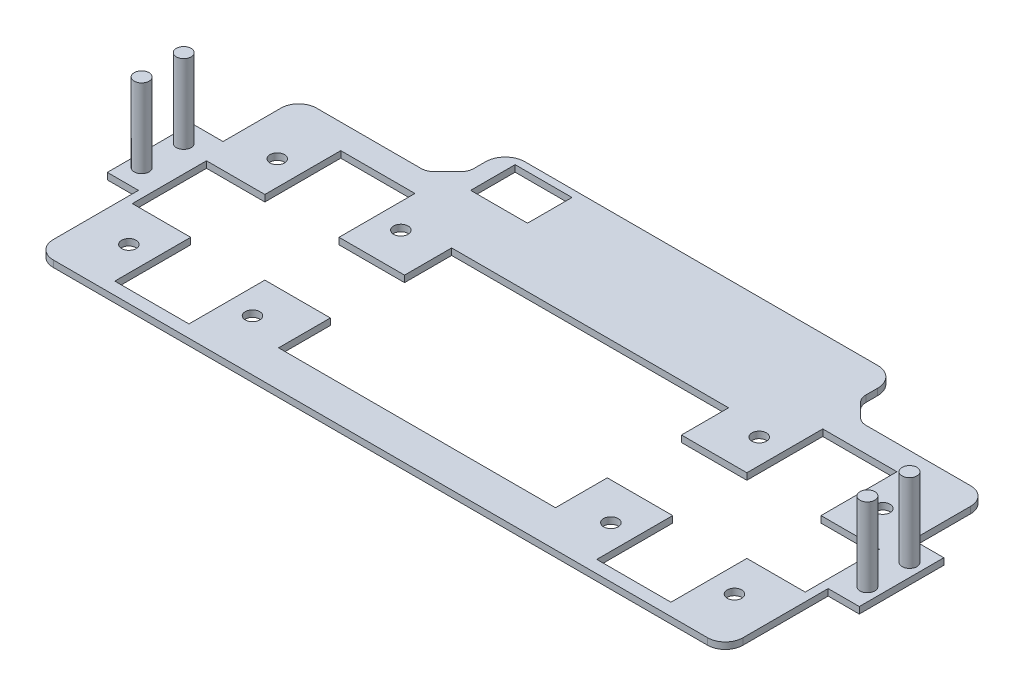
from build123d import *

# Parameters (mm, degrees)
BOSS_EXTRUDE1_DEPTH = 5
SCALE2_SCALE        = 0.265
SKETCH6_W           = 6.3
SKETCH6_H           = 17.1
BOSS_EXTRUDE2_DEPTH = 1.325
SKETCH5_W           = 11.5
SKETCH5_H           = 9
SKETCH5_R           = 1.468522593
CUT_EXTRUDE1_DEPTH  = 1.325
SKETCH8_R           = 1.5
BOSS_EXTRUDE5_DEPTH = 15.9


with BuildPart() as part:
    # Sketch1 → Boss-Extrude1 (new body)
    with BuildSketch(Plane(origin=(0, 0, 0), x_dir=(1, 0, 0), z_dir=(0, 1, 0))):
        with BuildLine():
            Line((-247.677130459, 9.093460821), (0, 9.093460821))
            Line((0, 9.093460821), (1.981474539, 9.093460821))
            Line((1.981474539, 9.093460821), (3.962949079, 9.093460821))
            Line((3.962949079, 9.093460821), (251.640079537, 9.093460821))
            ThreePointArc((251.640079537, 9.093460821), (261.186021083, 13.047519275), (265.140079537, 22.593460821))
            Line((265.140079537, 22.593460821), (265.140079537, 87.593460821))
            Line((265.140079537, 87.593460821), (265.140079537, 152.207743366))
            Line((265.140079537, 152.207743366), (265.140079537, 196.397667024))
            ThreePointArc((265.140079537, 196.397667024), (261.186021083, 205.94360857), (251.640079537, 209.897667024))
            Line((251.640079537, 209.897667024), (171.71214435, 209.897667024))
            ThreePointArc((171.71214435, 209.897667024), (167.885310027, 210.658871699), (164.641076538, 212.826599212))
            Line((164.641076538, 212.826599212), (154.53187981, 222.935795941))
            ThreePointArc((154.53187981, 222.935795941), (152.364152296, 226.180029429), (151.602947621, 230.006863753))
            Line((151.602947621, 230.006863753), (151.602947621, 238.96110688))
            ThreePointArc((151.602947621, 238.96110688), (147.209549339, 249.567708598), (136.602947621, 253.96110688))
            Line((136.602947621, 253.96110688), (3.962949079, 253.96110688))
            Line((3.962949079, 253.96110688), (0, 253.96110688))
            Line((0, 253.96110688), (-132.639998543, 253.96110688))
            ThreePointArc((-132.639998543, 253.96110688), (-143.246600261, 249.567708598), (-147.639998543, 238.96110688))
            Line((-147.639998543, 238.96110688), (-147.639998543, 230.006863753))
            ThreePointArc((-147.639998543, 230.006863753), (-148.401203218, 226.180029429), (-150.568930731, 222.935795941))
            Line((-150.568930731, 222.935795941), (-160.67812746, 212.826599212))
            ThreePointArc((-160.67812746, 212.826599212), (-163.922360948, 210.658871699), (-167.749195272, 209.897667024))
            Line((-167.749195272, 209.897667024), (-247.677130459, 209.897667024))
            ThreePointArc((-247.677130459, 209.897667024), (-257.223072005, 205.94360857), (-261.177130459, 196.397667024))
            Line((-261.177130459, 196.397667024), (-261.177130459, 152.207743366))
            Line((-261.177130459, 152.207743366), (-261.177130459, 87.593460821))
            Line((-261.177130459, 87.593460821), (-261.177130459, 22.593460821))
            ThreePointArc((-261.177130459, 22.593460821), (-257.223072005, 13.047519275), (-247.677130459, 9.093460821))
        make_face()
    extrude(amount=BOSS_EXTRUDE1_DEPTH)


with BuildPart() as part_1:
    # Scale2: scaled about (0, 0, 0)
    add(part.part.scale(SCALE2_SCALE))

    # Sketch6 → Boss-Extrude2 (add)
    with BuildSketch(Plane(origin=(0, 1.325, 0), x_dir=(1, 0, 0), z_dir=(0, 1, 0))):
        with Locations((-72.361939572, 31.762267118)):
            Rectangle(SKETCH6_W, SKETCH6_H)
        with Locations((73.412121077, 31.762267118)):
            Rectangle(SKETCH6_W, SKETCH6_H)
    extrude(amount=-BOSS_EXTRUDE2_DEPTH)

    # Sketch5 → Cut-Extrude1 (cut)
    with BuildSketch(Plane(origin=(0, 1.325, 0), x_dir=(1, 0, 0), z_dir=(0, 1, 0))):
        Polygon((-67.511939572, 27.772881761), (-67.511939572, 20.272881761), (-55.711939572, 20.272881761), (-55.711939572, 4.922881761), (-40.711939572, 4.922881761), (-40.711939572, 20.272881761), (-27.461939572, 20.272881761), (-27.461939572, 9.799693323), (28.538060428, 9.799693323), (28.538060428, 20.272881761), (41.762121077, 20.272881761), (41.762121077, 4.922881761), (56.762121077, 4.922881761), (56.762121077, 20.272881761), (68.562121077, 20.272881761), (68.562121077, 35.272881761), (56.762121077, 35.272881761), (56.762121077, 50.622881761), (41.762121077, 50.622881761), (41.762121077, 35.272881761), (28.538060428, 35.272881761), (28.538060428, 44.799693323), (-27.461939572, 44.799693323), (-27.461939572, 35.272881761), (-40.711939572, 35.272881761), (-40.711939572, 50.622881761), (-55.711939572, 50.622881761), (-55.711939572, 35.272881761), (-67.511939572, 35.272881761), align=None)
        with Locations((-29.874599614, 61.299693323)):
            Rectangle(SKETCH5_W, SKETCH5_H)
        with Locations((-35.711939572, 42.772881761)):
            Circle(SKETCH5_R)
        with Locations((-60.711939572, 42.772881761)):
            Circle(SKETCH5_R)
        with Locations((-60.711939572, 12.772881761)):
            Circle(SKETCH5_R)
        with Locations((-35.711939572, 12.772881761)):
            Circle(SKETCH5_R)
        with Locations((36.762121077, 12.772881761)):
            Circle(SKETCH5_R)
        with Locations((61.762121077, 12.772881761)):
            Circle(SKETCH5_R)
        with Locations((36.762121077, 42.772881761)):
            Circle(SKETCH5_R)
        with Locations((61.762121077, 42.772881761)):
            Circle(SKETCH5_R)
    extrude(amount=-CUT_EXTRUDE1_DEPTH, mode=Mode.SUBTRACT)

    # Sketch8 → Boss-Extrude5 (add)
    with BuildSketch(Plane(origin=(0, 1.325, 0), x_dir=(1, 0, 0), z_dir=(0, 1, 0))):
        with Locations((-72.861939572, 36.019267118)):
            Circle(SKETCH8_R)
        with Locations((-72.861939572, 27.505267118)):
            Circle(SKETCH8_R)
        with Locations((73.912121077, 36.019267118)):
            Circle(SKETCH8_R)
        with Locations((73.912121077, 27.505267118)):
            Circle(SKETCH8_R)
    extrude(amount=BOSS_EXTRUDE5_DEPTH)


solid = part_1.part
